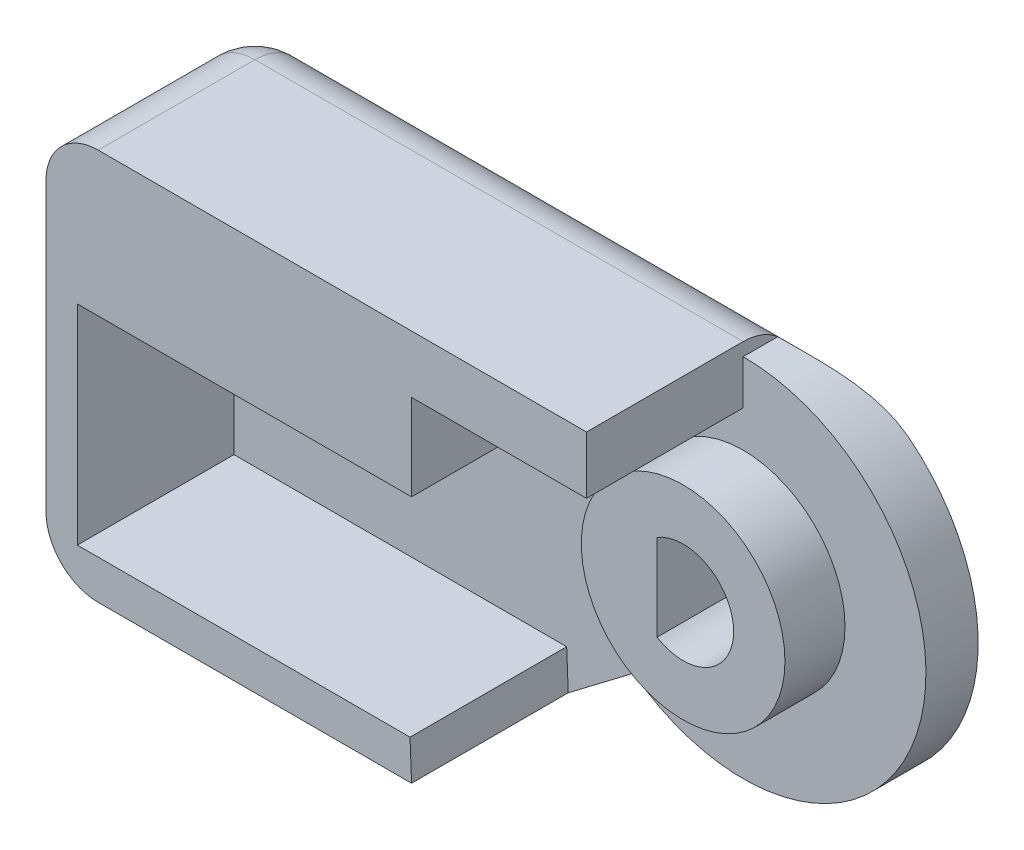
from build123d import *

# Parameters (mm, degrees)
BOSS_EXTRUDE1_DEPTH = 2
BOSS_EXTRUDE2_DEPTH = 6
SKETCH24_R          = 3.9
BOSS_EXTRUDE5_DEPTH = 2.3
SKETCH30_W          = 2.408612022
SKETCH30_H          = 1.324178481
CUT_EXTRUDE12_DEPTH = 8
FILLET2_R           = 2
CUT_EXTRUDE11_DEPTH = 10


with BuildPart() as part:
    # Sketch2 → Boss-Extrude1 (new body)
    with BuildSketch(Plane.XY):
        with BuildLine():
            Line((-2.5, 7.5), (-20.7, 7.5))
            Line((-20.7, 7.5), (-20.7, -7.5))
            Line((-20.7, -7.5), (-6.7, -7.5))
            Line((-6.7, -7.5), (-4.2, -5.6))
            ThreePointArc((-4.2, -5.6), (3.130495168, -6.260990337), (7, 0))
            ThreePointArc((7, 0), (4.949747468, 4.949747468), (0, 7))
            Line((0, 7), (0, 7.5))
            Line((0, 7.5), (-2.5, 7.5))
        make_face()
    extrude(amount=BOSS_EXTRUDE1_DEPTH)

    # Sketch4 → Boss-Extrude2 (add)
    with BuildSketch(Plane.XY.offset(2)):
        Polygon((-20.7, -7.5), (-20.7, 7.5), (-0.7, 7.5), (0, 7.5), (0, 5.3), (-0.7, 5.3), (-6.7, 5.3), (-6.7, 2), (-19.5, 2), (-19.5, -6), (-6.759079174, -6), (-6.7, -7.5), (-19.292624541, -7.5), align=None)
    extrude(amount=BOSS_EXTRUDE2_DEPTH)

    # Sketch24 → Boss-Extrude5 (add)
    with BuildSketch(Plane.XY.offset(2)):
        Circle(SKETCH24_R)
    extrude(amount=BOSS_EXTRUDE5_DEPTH)

    # Sketch30 → Cut-Extrude12 (cut)
    with BuildSketch(Plane(origin=(-6.7, 0, 0), x_dir=(0, 0, -1), z_dir=(1, 0, 0))):
        with Locations((-3.261593395, 4.63791076)):
            Rectangle(SKETCH30_W, SKETCH30_H)
    extrude(amount=-CUT_EXTRUDE12_DEPTH, mode=Mode.SUBTRACT)

    # Fillet2
    fillet2_edges = [part.edges().sort_by_distance(p)[0] for p in [
        (-20.7, 0, 0),
        (-20.7, 7.5, 4),
        (-13.7, -7.5, 0),
        (-10.35, 7.5, 0),
        (-20.7, -7.5, 4),
    ]]
    fillet(fillet2_edges, radius=FILLET2_R)

    # Sketch28 → Cut-Extrude11 (cut)
    with BuildSketch(Plane.XY.offset(4.3)):
        with BuildLine():
            Line((-1, 1.656278148), (-1, -1.656278148))
            ThreePointArc((-1, -1.656278148), (1.934749933, 0), (-1, 1.656278148))
        make_face()
    extrude(amount=-CUT_EXTRUDE11_DEPTH, mode=Mode.SUBTRACT)


solid = part.part
